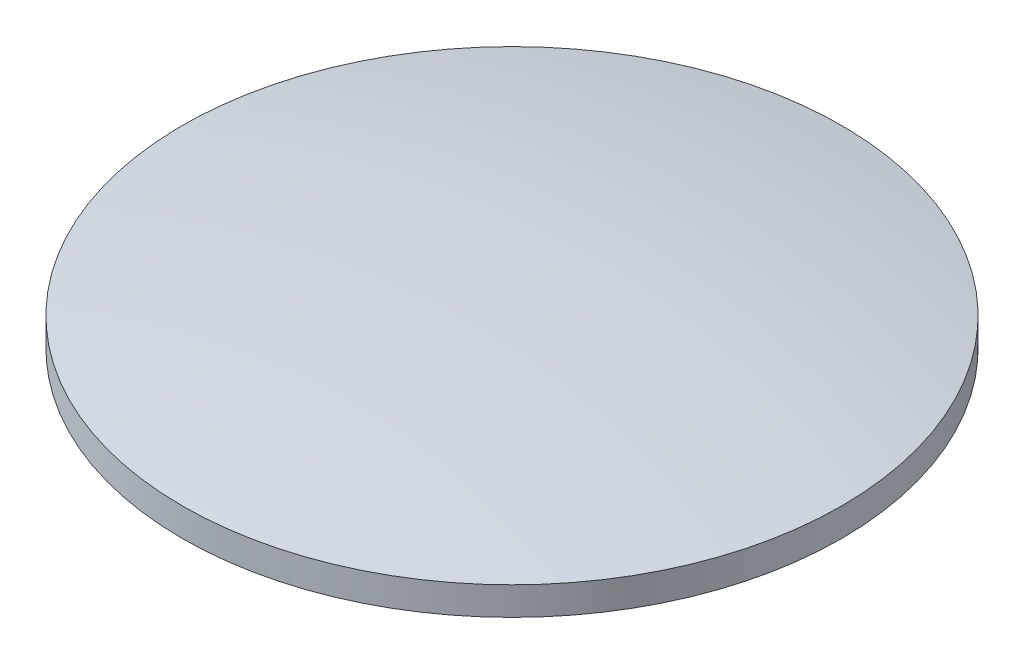
from build123d import *


with BuildPart() as part:
    # Sketch1 → Revolve7 (revolve)
    with BuildSketch(Plane.XY):
        with BuildLine():
            Line((0, 5), (0, -5))
            ThreePointArc((0, -5), (17.587282337, -4.12282337), (35, -1.5))
            Line((35, -1.5), (35, 1.5))
            ThreePointArc((35, 1.5), (17.587282337, 4.12282337), (0, 5))
        make_face()
    revolve(axis=Axis((0, 38.871213559, 0), (0, -1, 0)))


solid = part.part
